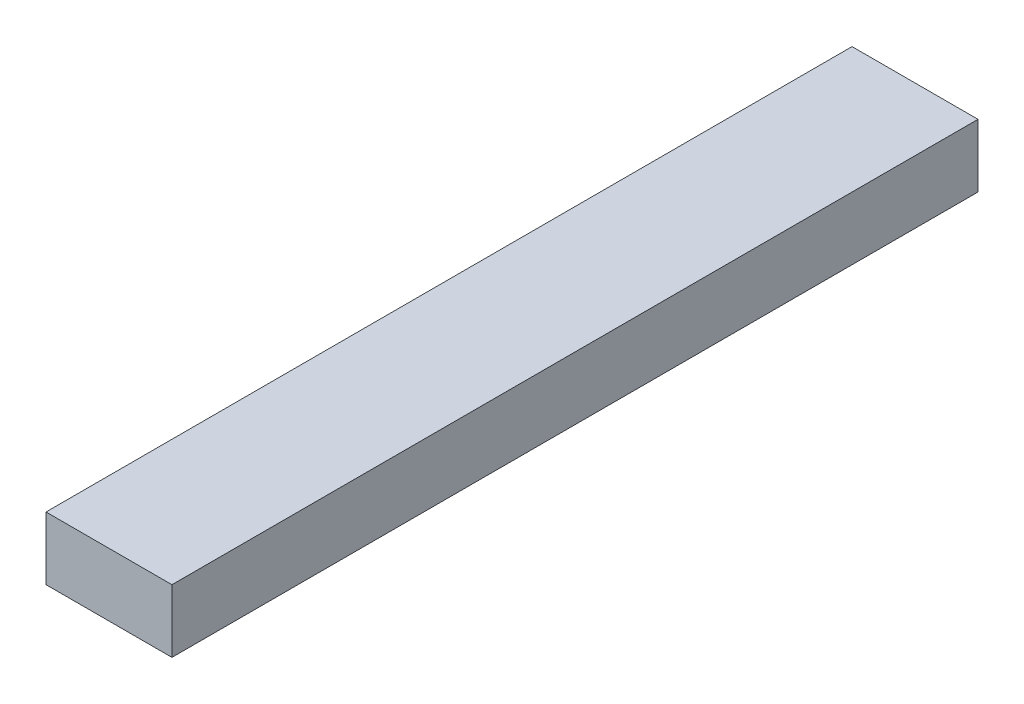
from build123d import *

# Parameters (mm, degrees)
SKETCH1_W           = 100
SKETCH1_H           = 50
BOSS_EXTRUDE1_DEPTH = 640


with BuildPart() as part:
    # Sketch1 → Boss-Extrude1 (new body)
    with BuildSketch(Plane.XY):
        Rectangle(SKETCH1_W, SKETCH1_H)
    extrude(amount=BOSS_EXTRUDE1_DEPTH)


solid = part.part
